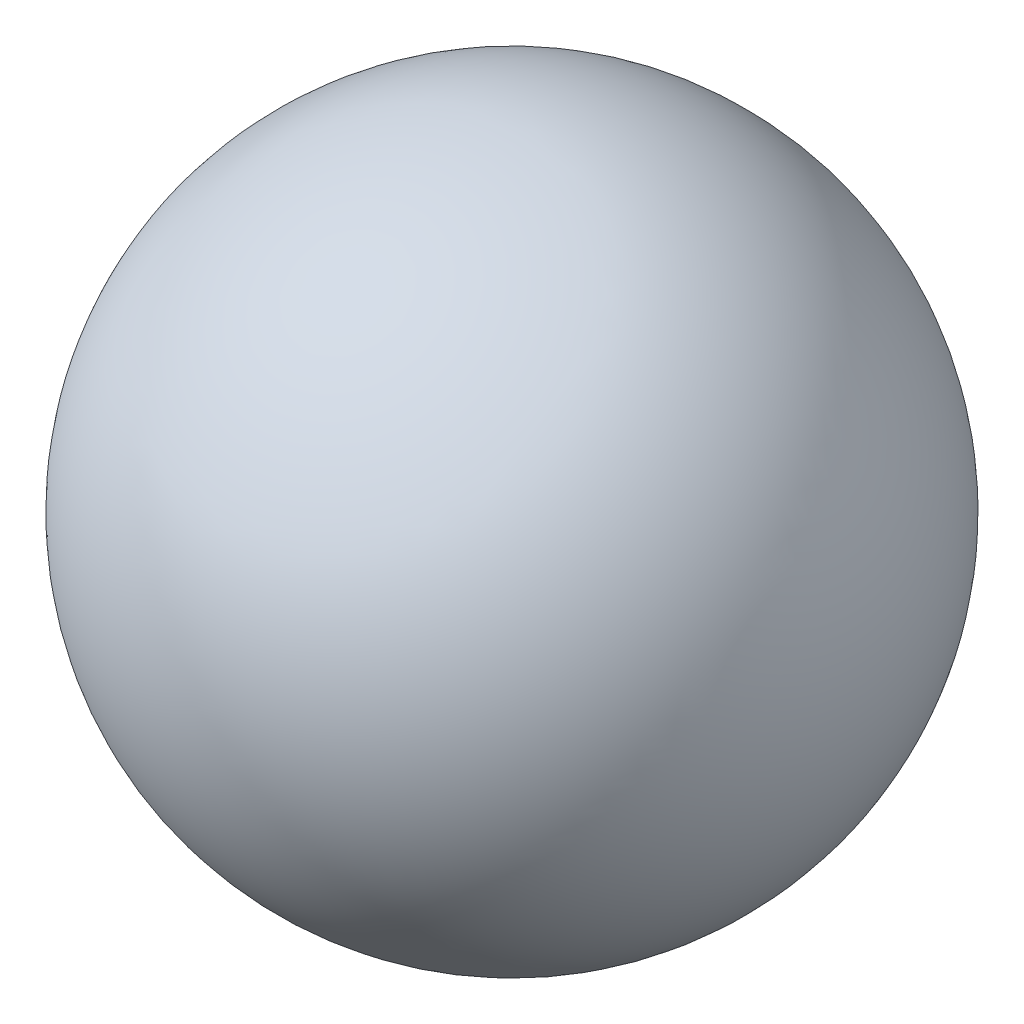
from build123d import *


with BuildPart() as part:
    # Sketch1 → Revolve1 (revolve)
    with BuildSketch(Plane.XY):
        with BuildLine():
            Line((-21.35, 0), (21.35, 0))
            ThreePointArc((21.35, 0), (0, 21.35), (-21.35, 0))
        make_face()
    revolve(axis=Axis((-21.35, 0, 0), (1, 0, 0)))


solid = part.part
